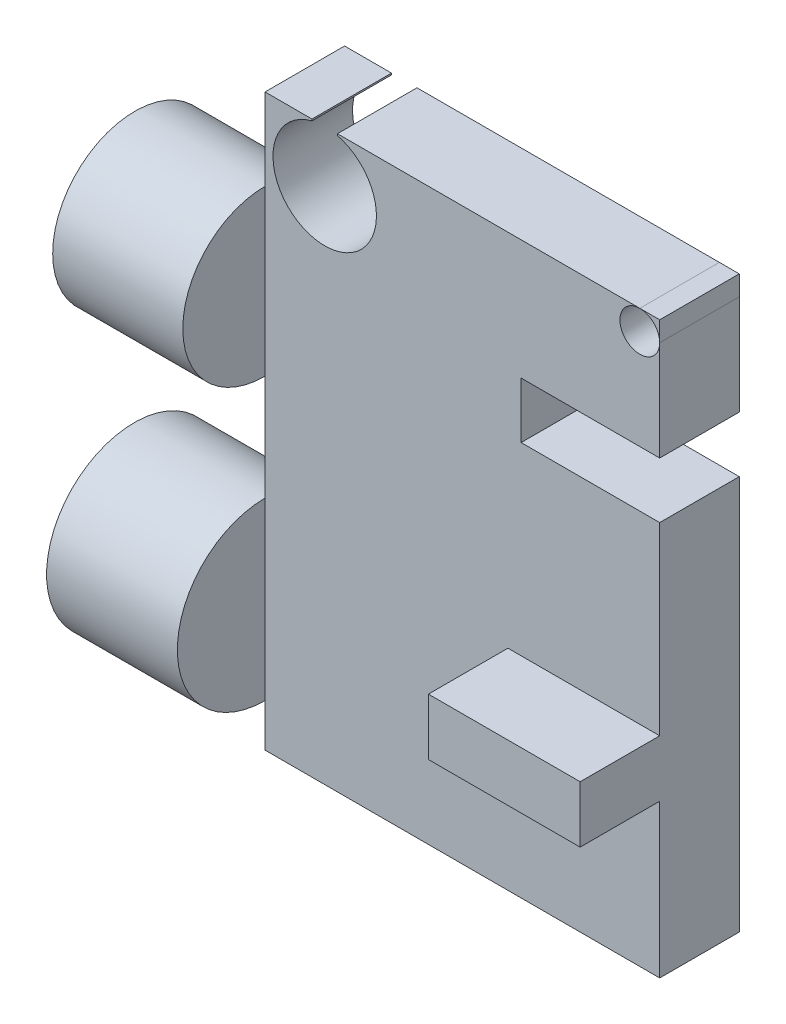
from build123d import *

# Parameters (mm, degrees)
SKETCH_1_W          = 49.610297338
SKETCH_1_H          = 71.655608821
EXTRUDE_1_DEPTH     = 10
SKETCH_2_W          = 16.35634768
SKETCH_2_H          = 10.339143633
SKETCH_3_W          = 16.438776978
SKETCH_3_H          = 11.021917269
SKETCH_4_W          = 17.418282618
SKETCH_4_H          = 7.022814543
CUT_EXTRUDE_1_DEPTH = 10
SKETCH_4_3_W        = 19.076447163
SKETCH_4_3_H        = 7.120353633
EXTRUDE_2_DEPTH     = 10
CUT_EXTRUDE_3_DEPTH = 99.073896393
SKETCH_6_R          = 2.5
CUT_EXTRUDE_4_DEPTH = 99.073896393


with BuildPart() as part:
    # 草图1 → 凸台-拉伸1 (new body)
    with BuildSketch(Plane.XY):
        with Locations((-24.805148669, 35.827804411)):
            Rectangle(SKETCH_1_W, SKETCH_1_H)
    extrude(amount=EXTRUDE_1_DEPTH)

    # 草图2 → 旋转1 (revolve)
    with BuildSketch(Plane.XY.offset(10)):
        with Locations((-57.788471178, 56.213474404)):
            Rectangle(SKETCH_2_W, SKETCH_2_H)
    revolve(axis=Axis((-65.966645018, 51.043902587, 10), (1, 0, 0)))

    # 草图3 → 旋转2 (revolve)
    with BuildSketch(Plane.XY.offset(10)):
        with Locations((-57.829685827, 21.928483961)):
            Rectangle(SKETCH_3_W, SKETCH_3_H)
    revolve(axis=Axis((-49.610297338, 16.417525326, 10), (-1, 0, 0)))

    # 草图4 → 切除-拉伸1 (cut)
    with BuildSketch(Plane.XY.offset(10)):
        with Locations((-8.709141309, 53.092223496)):
            Rectangle(SKETCH_4_W, SKETCH_4_H)
    extrude(amount=-CUT_EXTRUDE_1_DEPTH, mode=Mode.SUBTRACT)

    # 草图4<3> → 凸台-拉伸2 (add)
    with BuildSketch(Plane.XY.offset(10)):
        with Locations((-9.538223582, 22.806335779)):
            Rectangle(SKETCH_4_3_W, SKETCH_4_3_H)
    extrude(amount=EXTRUDE_2_DEPTH)

    # 草图5 → 切除-拉伸3 (cut, through all)
    with BuildSketch(Plane.XY.offset(10)):
        with BuildLine():
            Line((-43.710297338, 71.655608821), (-43.710297338, 71.455608821))
            ThreePointArc((-43.710297338, 71.455608821), (-42.110297338, 58.655608821), (-40.510297338, 71.455608821))
            Line((-40.510297338, 71.455608821), (-40.510297338, 71.655608821))
            Line((-40.510297338, 71.655608821), (-43.710297338, 71.655608821))
        make_face()
    extrude(amount=-CUT_EXTRUDE_3_DEPTH, mode=Mode.SUBTRACT)

    # 草图6 → 切除-拉伸4 (cut, through all)
    with BuildSketch(Plane.XY.offset(10)):
        with Locations((-2.5, 69.155608821)):
            Circle(SKETCH_6_R)
    extrude(amount=-CUT_EXTRUDE_4_DEPTH, mode=Mode.SUBTRACT)


with BuildPart() as cut_extrude_4_piece_1:
    # of the separate pieces the step leaves, piece 1, a body of its own (cut_extrude_4_pieces)
    add(part.part.solids().sort_by_distance((0, 0, 0))[0])


with BuildPart() as cut_extrude_4_piece_2:
    # of the separate pieces the step leaves, piece 2, a body of its own (cut_extrude_4_pieces)
    add(part.part.solids().sort_by_distance((0, 71.655608821, 0))[0])


solid = Compound([cut_extrude_4_piece_1.part, cut_extrude_4_piece_2.part])
